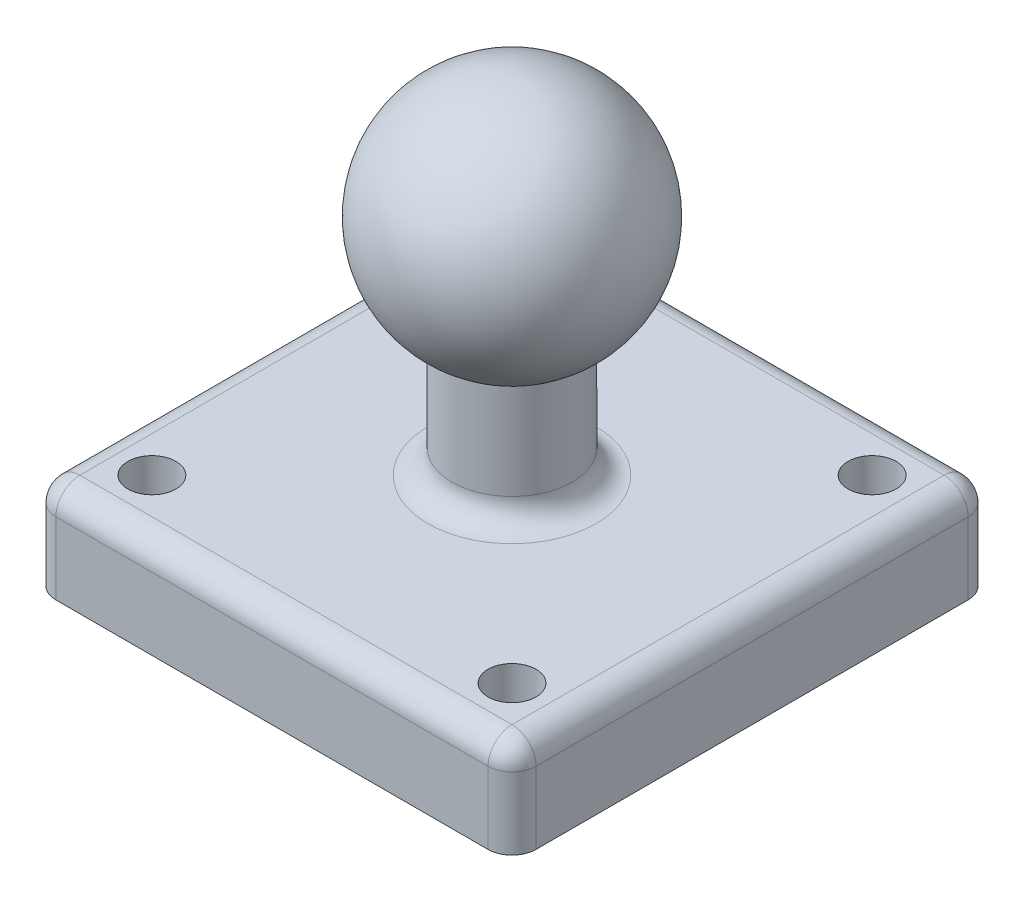
from build123d import *

# Parameters (mm, degrees)
ESQUISSE2_W             = 20
ESQUISSE2_H             = 20
BOSS_EXTRU_1_DEPTH      = 4
ENL_V_MAT_EXTRU_1_REACH = 6
ESQUISSE3_R             = 1
CONG_1_R                = 1


with BuildPart() as part:
    # Esquisse1 → Révolution1 (revolve)
    with BuildSketch(Plane.XY):
        with BuildLine():
            Line((-2.5, -4.330127019), (-2.5, -9.330127019))
            Line((-2.5, -9.330127019), (0, -9.330127019))
            Line((0, -9.330127019), (0, 5))
            ThreePointArc((0, 5), (-4.829629131, 1.294095226), (-2.5, -4.330127019))
        make_face()
    revolve(axis=Axis((0, -9.330127019, 0), (0, 1, 0)))

    # Esquisse2 → Boss.-Extru.1 (add)
    with BuildSketch(Plane.XZ.offset(9.330127019)):
        Rectangle(ESQUISSE2_W, ESQUISSE2_H)
    extrude(amount=BOSS_EXTRU_1_DEPTH)

    # Esquisse3 → Enlèv. mat.-Extru.1 (cut, up to next)
    with BuildSketch(Plane(origin=(0, -9.330127019, 0), x_dir=(1, 0, 0), z_dir=(0, 1, 0)), mode=Mode.PRIVATE) as enl_v_mat_extru_1_sk1:
        with Locations(Location((7.5, -7.5, 0), (0, 0, 180))):  # turned: the seam where the file's is
            Circle(ESQUISSE3_R)
    enl_v_mat_extru_1_tool1 = extrude(enl_v_mat_extru_1_sk1.sketch, amount=-ENL_V_MAT_EXTRU_1_REACH, mode=Mode.PRIVATE) & part.part
    add(enl_v_mat_extru_1_tool1.solids().sort_by_distance((7.5, -9.330127, 7.5))[0], mode=Mode.SUBTRACT)
    # Esquisse3 → Enlèv. mat.-Extru.1 (cut, up to next)
    with BuildSketch(Plane(origin=(0, -9.330127019, 0), x_dir=(1, 0, 0), z_dir=(0, 1, 0)), mode=Mode.PRIVATE) as enl_v_mat_extru_1_sk2:
        with Locations(Location((7.5, 7.5, 0), (0, 0, 180))):  # turned: the seam where the file's is
            Circle(ESQUISSE3_R)
    enl_v_mat_extru_1_tool2 = extrude(enl_v_mat_extru_1_sk2.sketch, amount=-ENL_V_MAT_EXTRU_1_REACH, mode=Mode.PRIVATE) & part.part
    add(enl_v_mat_extru_1_tool2.solids().sort_by_distance((7.5, -9.330127, -7.5))[0], mode=Mode.SUBTRACT)
    # Esquisse3 → Enlèv. mat.-Extru.1 (cut, up to next)
    with BuildSketch(Plane(origin=(0, -9.330127019, 0), x_dir=(1, 0, 0), z_dir=(0, 1, 0)), mode=Mode.PRIVATE) as enl_v_mat_extru_1_sk3:
        with Locations(Location((-7.5, 7.5, 0), (0, 0, 180))):  # turned: the seam where the file's is
            Circle(ESQUISSE3_R)
    enl_v_mat_extru_1_tool3 = extrude(enl_v_mat_extru_1_sk3.sketch, amount=-ENL_V_MAT_EXTRU_1_REACH, mode=Mode.PRIVATE) & part.part
    add(enl_v_mat_extru_1_tool3.solids().sort_by_distance((-7.5, -9.330127, -7.5))[0], mode=Mode.SUBTRACT)
    # Esquisse3 → Enlèv. mat.-Extru.1 (cut, up to next)
    with BuildSketch(Plane(origin=(0, -9.330127019, 0), x_dir=(1, 0, 0), z_dir=(0, 1, 0)), mode=Mode.PRIVATE) as enl_v_mat_extru_1_sk4:
        with Locations(Location((-7.5, -7.5, 0), (0, 0, 180))):  # turned: the seam where the file's is
            Circle(ESQUISSE3_R)
    enl_v_mat_extru_1_tool4 = extrude(enl_v_mat_extru_1_sk4.sketch, amount=-ENL_V_MAT_EXTRU_1_REACH, mode=Mode.PRIVATE) & part.part
    add(enl_v_mat_extru_1_tool4.solids().sort_by_distance((-7.5, -9.330127, 7.5))[0], mode=Mode.SUBTRACT)

    # Congé1
    cong_1_edges = [part.edges().sort_by_distance(p)[0] for p in [
        (-10, -11.330127019, -10),
        (10, -9.330127019, 0),
        (10, -11.330127019, -10),
        (0, -9.330127019, 10),
        (10, -11.330127019, 10),
        (2.5, -9.330127019, 0),
        (-10, -9.330127019, 0),
        (-10, -11.330127019, 10),
        (0, -9.330127019, -10),
    ]]
    fillet(cong_1_edges, radius=CONG_1_R)


solid = part.part
